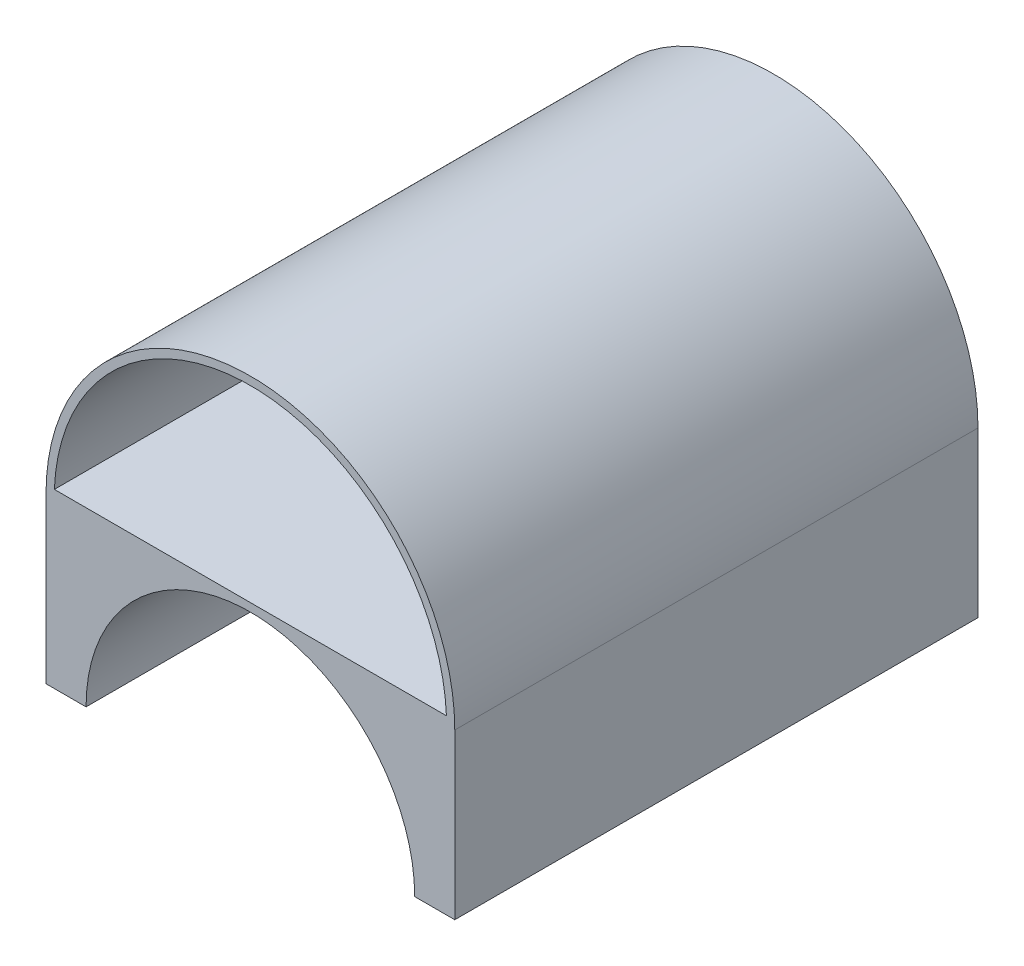
from build123d import *

# Parameters (mm, degrees)
BOSS_EXTRUDE1_DEPTH = 81.28
SHELL2_T            = -1.27
BOSS_EXTRUDE2_DEPTH = 81.28


with BuildPart() as part:
    # Sketch1 → Boss-Extrude1 (new body)
    with BuildSketch(Plane.XY):
        with BuildLine():
            Line((-31.75, 0), (31.75, 0))
            ThreePointArc((31.75, 0), (0, 31.75), (-31.75, 0))
        make_face()
    extrude(amount=-BOSS_EXTRUDE1_DEPTH)

    # Shell2
    shell2_openings = [part.faces().sort_by_distance(p)[0] for p in [
        (0, 13.475118515, 0),
    ]]
    offset(amount=SHELL2_T, openings=shell2_openings)

    # Sketch5 → Boss-Extrude2 (add)
    with BuildSketch(Plane.XY):
        with BuildLine():
            Line((-3.8e-08, 0), (-31.75, 0))
            Line((-31.75, 0), (-31.75, -25.527))
            Line((-31.75, -25.527), (-25.527, -25.527))
            ThreePointArc((-25.527, -25.527), (-18.050314817, -7.47668521), (-3.8e-08, 0))
        make_face()
        with BuildLine():
            Line((31.75, 0), (-3.8e-08, 0))
            ThreePointArc((-3.8e-08, 0), (18.05031479, -7.476685183), (25.527, -25.527))
            Line((25.527, -25.527), (31.75, -25.527))
            Line((31.75, -25.527), (31.75, 0))
        make_face()
    extrude(amount=-BOSS_EXTRUDE2_DEPTH)


solid = part.part
